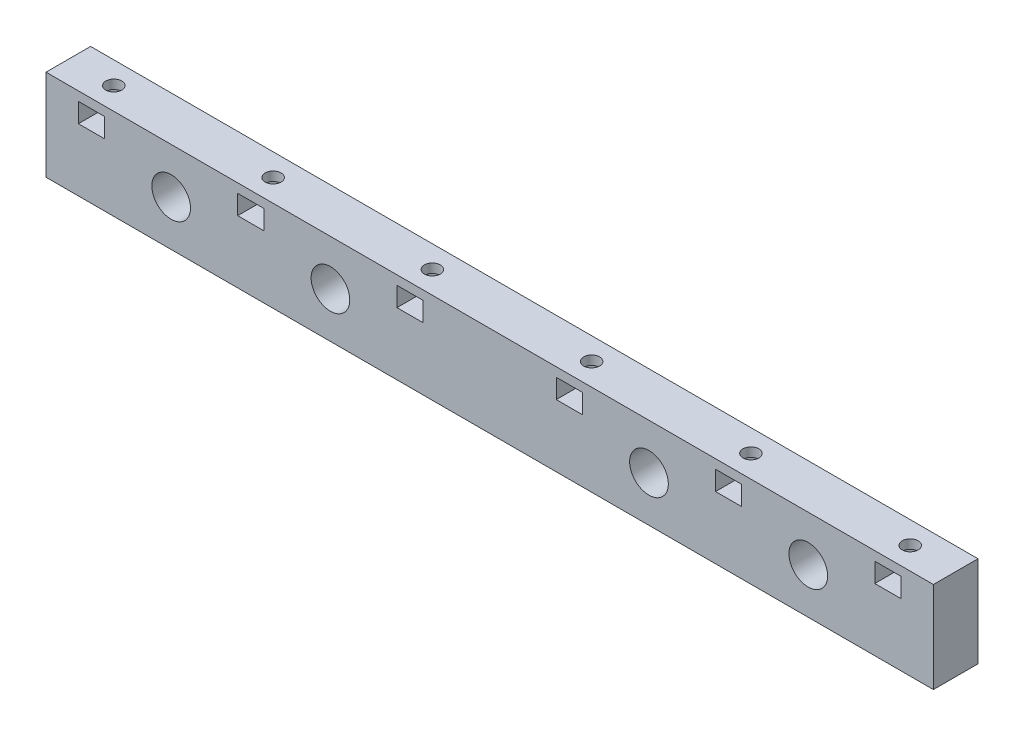
from build123d import *

# Parameters (mm, degrees)
SKETCH1_W               = 195
SKETCH1_H               = 20
BOSS_EXTRUDE1_DEPTH     = 4.9
SKETCH2_R               = 1.75
CUT_EXTRUDE1_DEPTH      = 6
CUT_EXTRUDE2_START      = -2
CUT_EXTRUDE2_DEPTH      = 4.25
SKETCH4_W               = 5.75
SKETCH4_H               = 4.25
CUT_EXTRUDE3_DEPTH      = 5.9
LPATTERN1_COUNT         = 3
LPATTERN1_PITCH         = 35
MIRROR1_COPY_1_SKETCH_R = 1.75
MIRROR1_COPY_1_DEPTH    = 6
MIRROR1_COPY_2_SKETCH_R = 1.75
MIRROR1_COPY_2_DEPTH    = 6
MIRROR1_START           = -2
MIRROR1_COPY_3_DEPTH    = 4.25
MIRROR1_COPY_4_DEPTH    = 4.25
MIRROR1_COPY_5_SKETCH_W = 5.75
MIRROR1_COPY_5_SKETCH_H = 4.25
MIRROR1_COPY_5_DEPTH    = 5.9
MIRROR1_COPY_6_SKETCH_W = 5.75
MIRROR1_COPY_6_SKETCH_H = 4.25
MIRROR1_COPY_6_DEPTH    = 5.9
SKETCH5_R               = 4.25
CUT_EXTRUDE4_DEPTH      = 6
CUT_EXTRUDE5_START      = -4.8
SKETCH6_R               = 2.625
CUT_EXTRUDE5_DEPTH      = 11.8
LPATTERN2_COUNT         = 2
LPATTERN2_PITCH         = 35
MIRROR2_COPY_1_SKETCH_R = 4.25
MIRROR2_COPY_1_DEPTH    = 6
MIRROR2_START           = -4.8
MIRROR2_COPY_2_SKETCH_R = 2.625
MIRROR2_COPY_2_DEPTH    = 11.8


with BuildPart() as part:
    # Sketch1 → Boss-Extrude1 (new body, symmetric)
    with BuildSketch(Plane.XY):
        Rectangle(SKETCH1_W, SKETCH1_H)
    extrude(amount=BOSS_EXTRUDE1_DEPTH, both=True)

    # Sketch2 → Cut-Extrude1 (cut)
    with BuildSketch(Plane(origin=(0, 10, 0), x_dir=(1, 0, 0), z_dir=(0, 1, 0))):
        with Locations((-87.5, 0)):
            Circle(SKETCH2_R)
    cut_extrude1 = extrude(amount=-CUT_EXTRUDE1_DEPTH, mode=Mode.SUBTRACT)

    # Sketch3 → Cut-Extrude2 (cut)
    with BuildSketch(Plane(origin=(0, 10, 0), x_dir=(1, 0, 0), z_dir=(0, 1, 0)).offset(CUT_EXTRUDE2_START)):
        Polygon((-87.5, 3.319764048), (-90.375, 1.659882024), (-90.375, -1.659882024), (-87.5, -3.319764048), (-84.625, -1.659882024), (-84.625, 1.659882024), align=None)
    cut_extrude2 = extrude(amount=-CUT_EXTRUDE2_DEPTH, mode=Mode.SUBTRACT)

    # Sketch4 → Cut-Extrude3 (cut, through all)
    with BuildSketch(Plane.XY):
        with Locations((-87.5, 5.875)):
            Rectangle(SKETCH4_W, SKETCH4_H)
    cut_extrude3 = extrude(amount=CUT_EXTRUDE3_DEPTH, mode=Mode.SUBTRACT)

    # LPattern1: Cut-Extrude1, Cut-Extrude2, Cut-Extrude3 ×3
    with Locations(*[(i * LPATTERN1_PITCH, 0, 0) for i in range(1, LPATTERN1_COUNT)]):
        add(cut_extrude1, mode=Mode.SUBTRACT)
        add(cut_extrude2, mode=Mode.SUBTRACT)
        add(cut_extrude3, mode=Mode.SUBTRACT)

    # Mirror1: Cut-Extrude1, Cut-Extrude2, Cut-Extrude3 across plane
    add(cut_extrude1.mirror(Plane(origin=(0, 0, 0), x_dir=(0, 0, 1), z_dir=(1, 0, 0))), mode=Mode.SUBTRACT)
    add(cut_extrude2.mirror(Plane(origin=(0, 0, 0), x_dir=(0, 0, 1), z_dir=(1, 0, 0))), mode=Mode.SUBTRACT)
    add(cut_extrude3.mirror(Plane(origin=(0, 0, 0), x_dir=(0, 0, 1), z_dir=(1, 0, 0))), mode=Mode.SUBTRACT)

    # Mirror1 copy 1 sketch → Mirror1 copy 1 (cut)
    with BuildSketch(Plane(origin=(-35, 10, 0), x_dir=(-1, 0, 0), z_dir=(0, 1, 0))):
        with Locations((-87.5, 0)):
            Circle(MIRROR1_COPY_1_SKETCH_R)
    extrude(amount=-MIRROR1_COPY_1_DEPTH, mode=Mode.SUBTRACT)

    # Mirror1 copy 2 sketch → Mirror1 copy 2 (cut)
    with BuildSketch(Plane(origin=(-70, 10, 0), x_dir=(-1, 0, 0), z_dir=(0, 1, 0))):
        with Locations((-87.5, 0)):
            Circle(MIRROR1_COPY_2_SKETCH_R)
    extrude(amount=-MIRROR1_COPY_2_DEPTH, mode=Mode.SUBTRACT)

    # Mirror1 copy 3 sketch → Mirror1 copy 3 (cut)
    with BuildSketch(Plane(origin=(-35, 10, 0), x_dir=(-1, 0, 0), z_dir=(0, 1, 0)).offset(MIRROR1_START)):
        Polygon((-87.5, -3.319764048), (-90.375, -1.659882024), (-90.375, 1.659882024), (-87.5, 3.319764048), (-84.625, 1.659882024), (-84.625, -1.659882024), align=None)
    extrude(amount=-MIRROR1_COPY_3_DEPTH, mode=Mode.SUBTRACT)

    # Mirror1 copy 4 sketch → Mirror1 copy 4 (cut)
    with BuildSketch(Plane(origin=(-70, 10, 0), x_dir=(-1, 0, 0), z_dir=(0, 1, 0)).offset(MIRROR1_START)):
        Polygon((-87.5, -3.319764048), (-90.375, -1.659882024), (-90.375, 1.659882024), (-87.5, 3.319764048), (-84.625, 1.659882024), (-84.625, -1.659882024), align=None)
    extrude(amount=-MIRROR1_COPY_4_DEPTH, mode=Mode.SUBTRACT)

    # Mirror1 copy 5 sketch → Mirror1 copy 5 (cut, through all)
    with BuildSketch(Plane(origin=(-35, 0, 0), x_dir=(-1, 0, 0), z_dir=(0, 0, 1))):
        with Locations((-87.5, -5.875)):
            Rectangle(MIRROR1_COPY_5_SKETCH_W, MIRROR1_COPY_5_SKETCH_H)
    extrude(amount=MIRROR1_COPY_5_DEPTH, mode=Mode.SUBTRACT)

    # Mirror1 copy 6 sketch → Mirror1 copy 6 (cut, through all)
    with BuildSketch(Plane(origin=(-70, 0, 0), x_dir=(-1, 0, 0), z_dir=(0, 0, 1))):
        with Locations((-87.5, -5.875)):
            Rectangle(MIRROR1_COPY_6_SKETCH_W, MIRROR1_COPY_6_SKETCH_H)
    extrude(amount=MIRROR1_COPY_6_DEPTH, mode=Mode.SUBTRACT)

    # Sketch5 → Cut-Extrude4 (cut)
    with BuildSketch(Plane.XY.offset(4.9)):
        with Locations((-70, 0)):
            Circle(SKETCH5_R)
    cut_extrude4 = extrude(amount=-CUT_EXTRUDE4_DEPTH, mode=Mode.SUBTRACT)

    # Sketch6 → Cut-Extrude5 (cut)
    with BuildSketch(Plane.XY.offset(-1.1).offset(CUT_EXTRUDE5_START)):
        with Locations((-70, 0)):
            Circle(SKETCH6_R)
    cut_extrude5 = extrude(amount=CUT_EXTRUDE5_DEPTH, mode=Mode.SUBTRACT)

    # LPattern2: Cut-Extrude4, Cut-Extrude5 ×2
    with Locations(*[(i * LPATTERN2_PITCH, 0, 0) for i in range(1, LPATTERN2_COUNT)]):
        add(cut_extrude4, mode=Mode.SUBTRACT)
        add(cut_extrude5, mode=Mode.SUBTRACT)

    # Mirror2: Cut-Extrude4, Cut-Extrude5 across plane
    add(cut_extrude4.mirror(Plane(origin=(0, 0, 0), x_dir=(0, 0, 1), z_dir=(1, 0, 0))), mode=Mode.SUBTRACT)
    add(cut_extrude5.mirror(Plane(origin=(0, 0, 0), x_dir=(0, 0, 1), z_dir=(1, 0, 0))), mode=Mode.SUBTRACT)

    # Mirror2 copy 1 sketch → Mirror2 copy 1 (cut)
    with BuildSketch(Plane(origin=(-35, 0, 4.9), x_dir=(-1, 0, 0), z_dir=(0, 0, 1))):
        with Locations((-70, 0)):
            Circle(MIRROR2_COPY_1_SKETCH_R)
    extrude(amount=-MIRROR2_COPY_1_DEPTH, mode=Mode.SUBTRACT)

    # Mirror2 copy 2 sketch → Mirror2 copy 2 (cut)
    with BuildSketch(Plane(origin=(-35, 0, -1.1), x_dir=(-1, 0, 0), z_dir=(0, 0, 1)).offset(MIRROR2_START)):
        with Locations((-70, 0)):
            Circle(MIRROR2_COPY_2_SKETCH_R)
    extrude(amount=MIRROR2_COPY_2_DEPTH, mode=Mode.SUBTRACT)


solid = part.part
